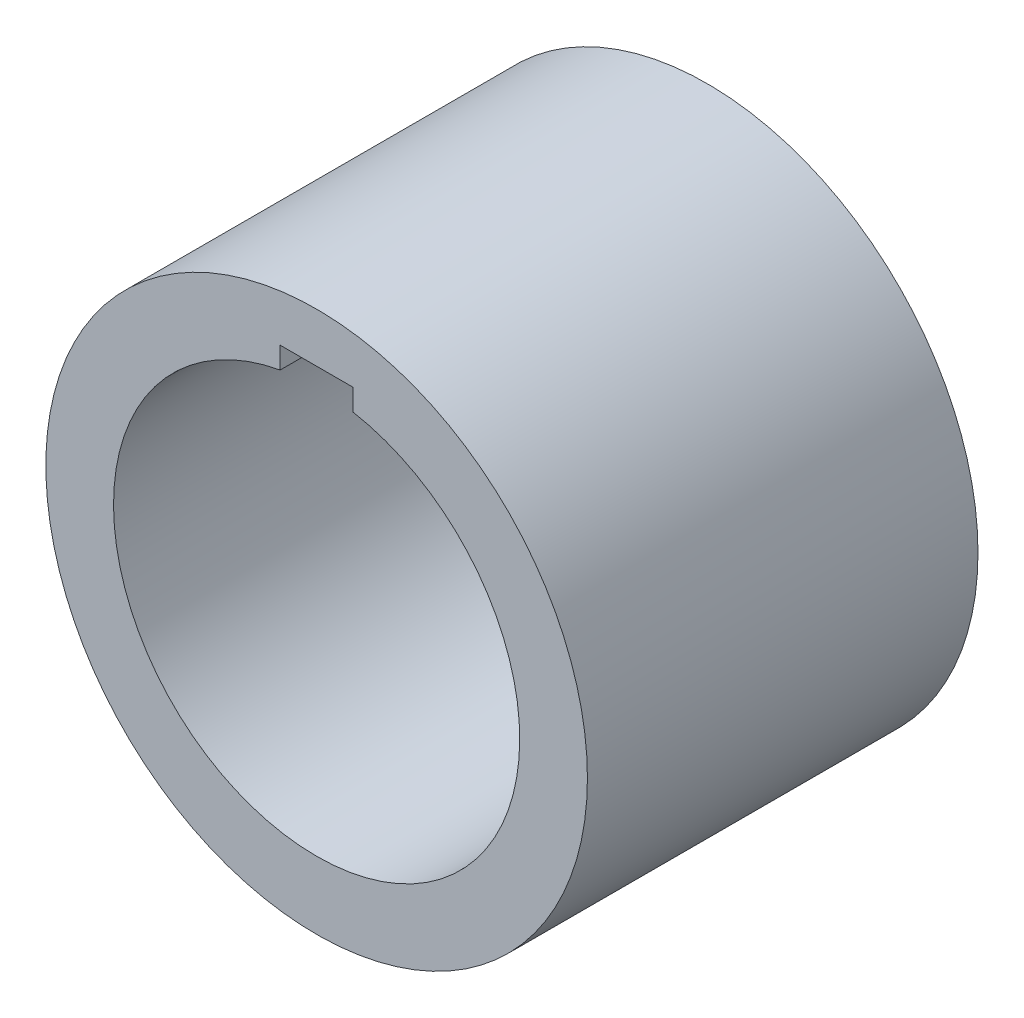
from build123d import *

# Parameters (mm, degrees)
SKETCH1_R           = 10.4
SKETCH1_R_2         = 7.8
BOSS_EXTRUDE1_DEPTH = 15
CUT_EXTRUDE1_REACH  = 17
SKETCH2_W           = 2.8
SKETCH2_H           = 2.8


with BuildPart() as part:
    # Sketch1 → Boss-Extrude1 (new body)
    with BuildSketch(Plane.XY):
        Circle(SKETCH1_R)
        Circle(SKETCH1_R_2, mode=Mode.SUBTRACT)
    extrude(amount=BOSS_EXTRUDE1_DEPTH)

    # Sketch2 → Cut-Extrude1 (cut, up to next)
    with BuildSketch(Plane.XY.offset(15), mode=Mode.PRIVATE) as cut_extrude1_sk1:
        with Locations((0, 7.1)):
            Rectangle(SKETCH2_W, SKETCH2_H)
    cut_extrude1_tool1 = extrude(cut_extrude1_sk1.sketch, amount=-CUT_EXTRUDE1_REACH, mode=Mode.PRIVATE) & part.part
    add(cut_extrude1_tool1.solids().sort_by_distance((0, 7.1, 15))[0], mode=Mode.SUBTRACT)


solid = part.part
